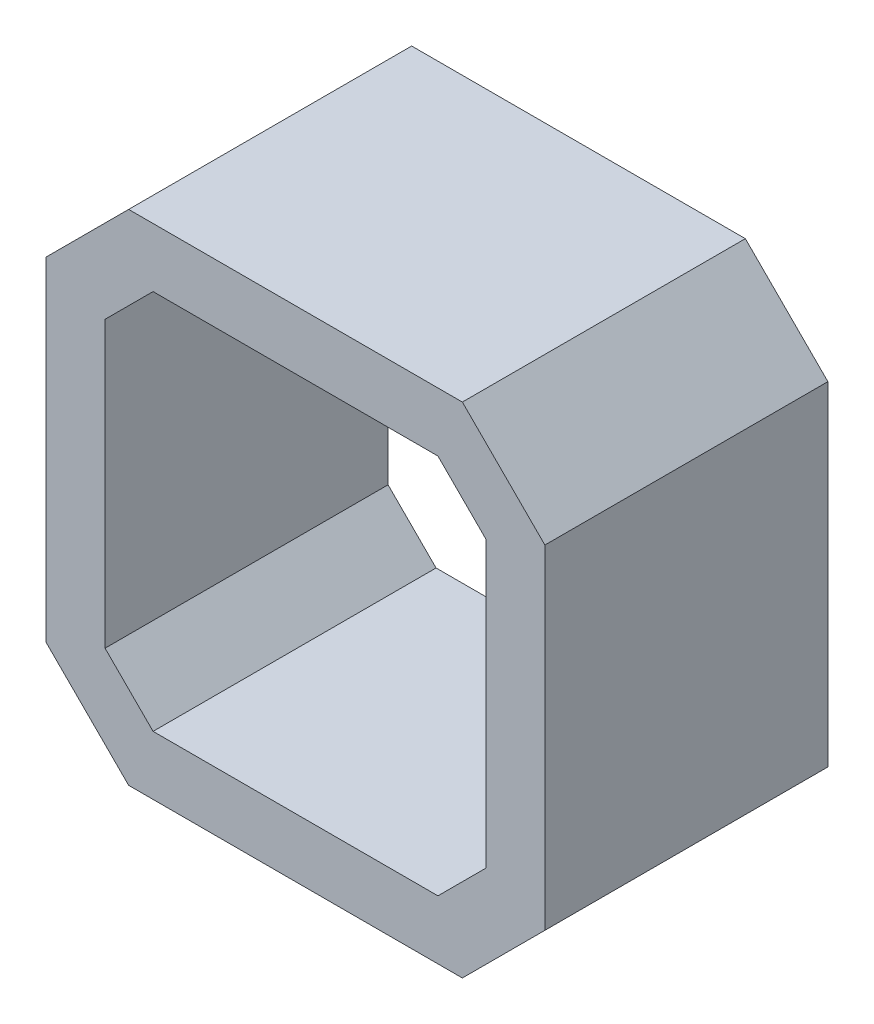
from build123d import *

# Parameters (mm, degrees)
BOSS_EXTRUDE1_DEPTH = 48


with BuildPart() as part:
    # Sketch1 → Boss-Extrude1 (new body)
    with BuildSketch(Plane.XY):
        Polygon((-42.3, 28.3), (-28.3, 42.3), (28.3, 42.3), (42.3, 28.3), (42.3, -28.3), (28.3, -42.3), (-28.3, -42.3), (-42.3, -28.3), align=None)
        Polygon((-24.157864376, 32.3), (24.157864376, 32.3), (32.3, 24.157864376), (32.3, -24.157864376), (24.157864376, -32.3), (-24.157864376, -32.3), (-32.3, -24.157864376), (-32.3, 24.157864376), align=None, mode=Mode.SUBTRACT)
    extrude(amount=BOSS_EXTRUDE1_DEPTH)


solid = part.part
